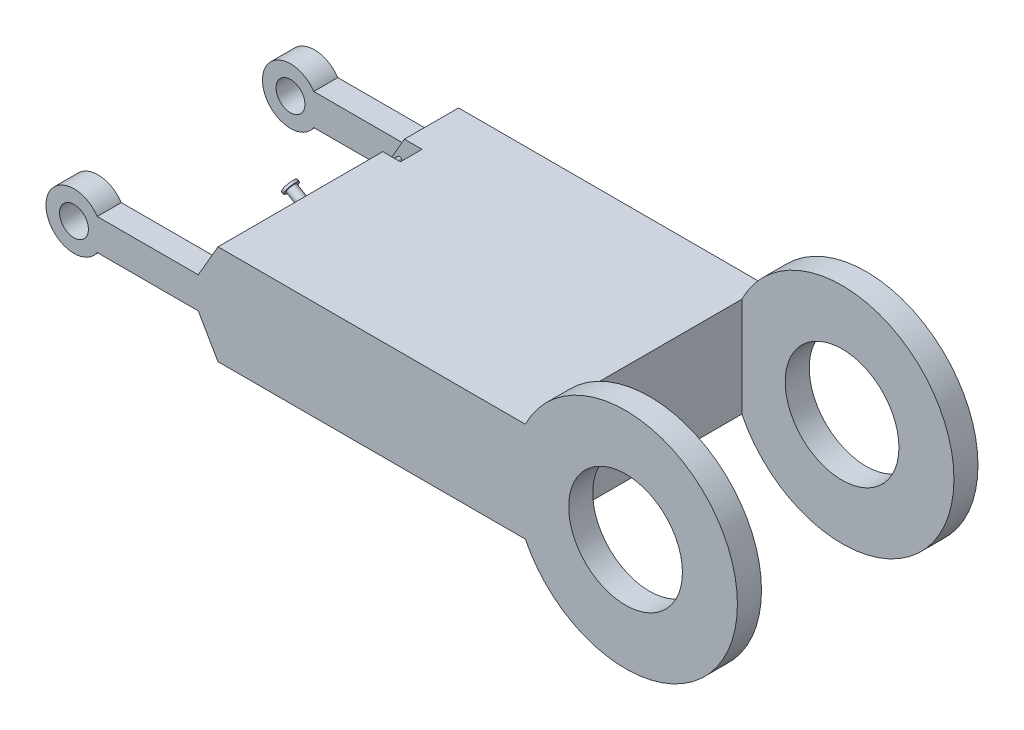
from build123d import *

# Parameters (mm, degrees)
BOSS_EXTRUDE4_DEPTH  = 40
SKETCH4_R            = 6
SKETCH4_R_2          = 23.64386934
BOSS_EXTRUDE5_DEPTH  = 10
SKETCH19_R           = 12.5
SKETCH19_R_2         = 1
CUT_EXTRUDE2_DEPTH   = 4.5
SKETCH21_R           = 2
BOSS_EXTRUDE7_DEPTH  = 8.5
SKETCH24_R           = 2
BOSS_EXTRUDE8_DEPTH  = 8.5
SKETCH26_R           = 12.5
CUT_EXTRUDE3_DEPTH   = 4.5
SKETCH32_R           = 1.5
BOSS_EXTRUDE10_DEPTH = 4.5
SKETCH33_R           = 3
BOSS_EXTRUDE11_DEPTH = 1
SKETCH34_R           = 3
BOSS_EXTRUDE12_DEPTH = 1


with BuildPart() as part:
    # Sketch1 → Boss-Extrude4 (new body)
    with BuildSketch(Plane.XY):
        Polygon((0, 0), (11.941837529, 20.683869337), (139.702763908, 20.683869337), (139.702763908, -20.683869337), (11.941837529, -20.683869337), align=None)
    extrude(amount=BOSS_EXTRUDE4_DEPTH)

    # Sketch4 → Boss-Extrude5 (add)
    with BuildSketch(Plane.XY.offset(40)):
        with BuildLine():
            Line((139.702763908, 20.683869337), (11.941837529, 20.683869337))
            Line((11.941837529, 20.683869337), (3.75277675, 6.5))
            Line((3.75277675, 6.5), (-38.24722325, 6.5))
            ThreePointArc((-38.24722325, 6.5), (-59.57399913, 0), (-38.24722325, -6.5))
            Line((-38.24722325, -6.5), (3.75277675, -6.5))
            Line((3.75277675, -6.5), (11.941837529, -20.683869337))
            Line((11.941837529, -20.683869337), (139.702763908, -20.683869337))
            ThreePointArc((139.702763908, -20.683869337), (227.866884071, 0), (139.702763908, 20.683869337))
        make_face()
        with Locations((-47.920072343, 0)):
            Circle(SKETCH4_R, mode=Mode.SUBTRACT)
        with Locations((181.358539635, 0)):
            Circle(SKETCH4_R_2, mode=Mode.SUBTRACT)
    extrude(amount=BOSS_EXTRUDE5_DEPTH)

    # Mirror2: part across plane


with BuildPart() as part_1:
    add(part.part)
    add(part.part.mirror(Plane.XY))

    # Sketch19 → Cut-Extrude2 (cut, symmetric)
    with BuildSketch(Plane.XY.offset(-23)):
        with Locations((9.87490508, 12.421300452)):
            Circle(SKETCH19_R)
        with Locations((9.87490508, 12.421300452)):
            Circle(SKETCH19_R_2, mode=Mode.SUBTRACT)
    extrude(amount=CUT_EXTRUDE2_DEPTH, both=True, mode=Mode.SUBTRACT)

    # Sketch21 → Boss-Extrude7 (add)
    with BuildSketch(Plane(origin=(0, 0, 0), x_dir=(0, 0, 1), z_dir=(-0.8660254037844399, 0.4999999999999979, 0))):
        with Locations(Location((7, 11.941837529, 0), (0, 0, 90))):
            Circle(SKETCH21_R)
    extrude(amount=BOSS_EXTRUDE7_DEPTH)

    # Sketch24 → Boss-Extrude8 (add)
    with BuildSketch(Plane(origin=(0, 0, 0), x_dir=(0, 0, 1), z_dir=(-0.8660254037844399, -0.49999999999999784, 0))):
        with Locations(Location((13, -11.941837529, 0), (0, 0, 90))):
            Circle(SKETCH24_R)
    extrude(amount=BOSS_EXTRUDE8_DEPTH)

    # Sketch26 → Cut-Extrude3 (cut, symmetric)
    with BuildSketch(Plane.XY.offset(-17)):
        with Locations((9.87490508, -12.421300452)):
            Circle(SKETCH26_R)
    extrude(amount=CUT_EXTRUDE3_DEPTH, both=True, mode=Mode.SUBTRACT)

    # Sketch33 → Boss-Extrude11 (add)
    with BuildSketch(Plane(origin=(-7.361215932, 4.25, 0), x_dir=(0, 0, 1), z_dir=(-0.8660254037844399, 0.49999999999999795, 0))):
        with Locations(Location((7, 11.941837529, 0), (0, 0, 270))):
            Circle(SKETCH33_R)
    extrude(amount=-BOSS_EXTRUDE11_DEPTH)

    # Sketch34 → Boss-Extrude12 (add)
    with BuildSketch(Plane(origin=(-7.361215932, -4.25, 0), x_dir=(0, 0, 1), z_dir=(-0.8660254037844399, -0.49999999999999784, 0))):
        with Locations(Location((13, -11.941837529, 0), (0, 0, 270))):
            Circle(SKETCH34_R)
    extrude(amount=-BOSS_EXTRUDE12_DEPTH)


with BuildPart() as body_2:
    # Sketch32 → Boss-Extrude10 (new, symmetric)
    with BuildSketch(Plane.XY.offset(-17)):
        with Locations((9.877833455, -12.426372546)):
            Circle(SKETCH32_R)
    extrude(amount=BOSS_EXTRUDE10_DEPTH, both=True)


solid = Compound([part_1.part, body_2.part])
